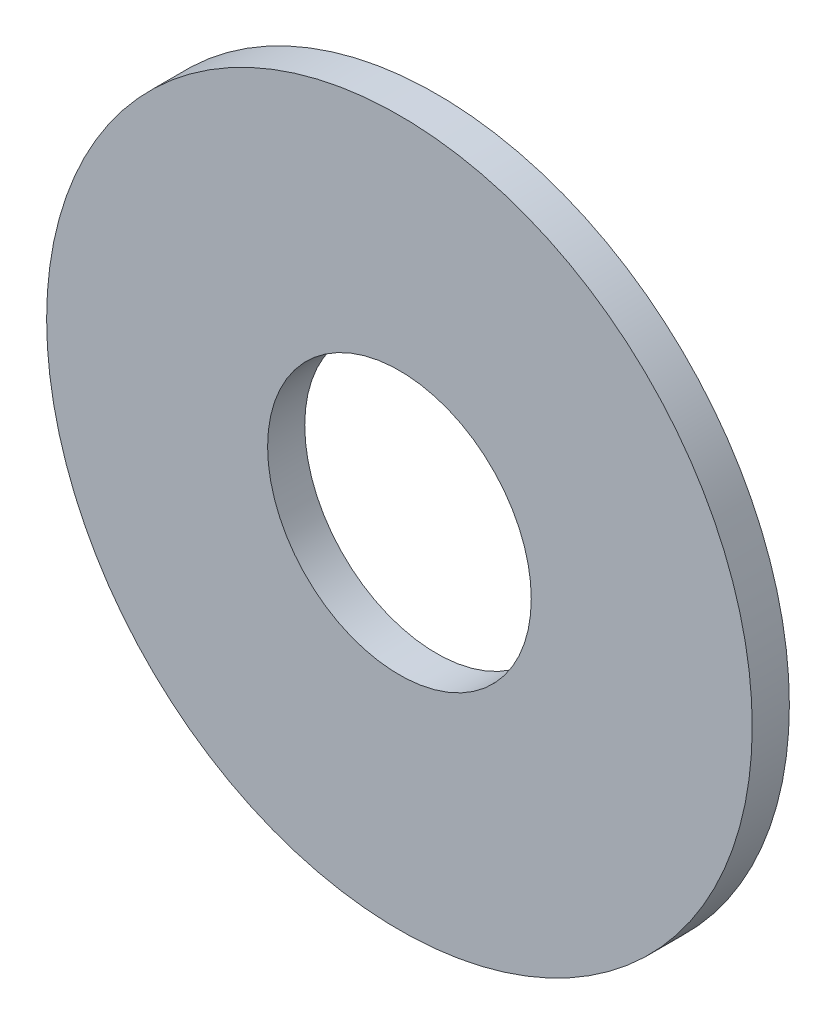
from build123d import *

# Parameters (mm, degrees)
SKIZZE1_R                       = 9.5
SKIZZE1_R_2                     = 3.55
AUFSATZ_LINEAR_AUSTRAGEN1_DEPTH = 1


with BuildPart() as part:
    # Skizze1 → Aufsatz-Linear austragen1 (new body)
    with BuildSketch(Plane.XY):
        Circle(SKIZZE1_R)
        Circle(SKIZZE1_R_2, mode=Mode.SUBTRACT)
    extrude(amount=AUFSATZ_LINEAR_AUSTRAGEN1_DEPTH)


solid = part.part
